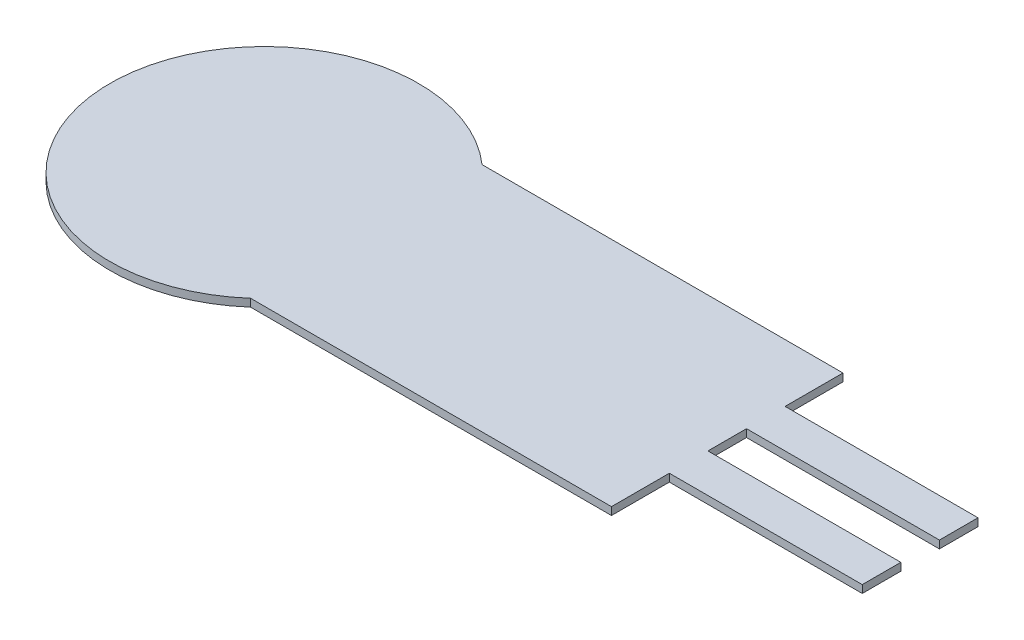
from build123d import *

# Parameters (mm, degrees)
SKETCH1_R           = 4
BOSS_EXTRUDE1_DEPTH = 0.1
SKETCH2_W           = 12
SKETCH2_H           = 6
BOSS_EXTRUDE2_DEPTH = 0.1
SKETCH3_W           = 5
SKETCH3_H           = 1
BOSS_EXTRUDE3_DEPTH = 0.1


with BuildPart() as part:
    # Sketch1 → Boss-Extrude1 (new body, symmetric)
    with BuildSketch(Plane(origin=(0, 0, 0), x_dir=(1, 0, 0), z_dir=(0, 1, 0))):
        Circle(SKETCH1_R)
    extrude(amount=BOSS_EXTRUDE1_DEPTH, both=True)

    # Sketch2 → Boss-Extrude2 (add, symmetric)
    with BuildSketch(Plane(origin=(0, 0, 0), x_dir=(1, 0, 0), z_dir=(0, 1, 0))):
        with Locations((6, 0)):
            Rectangle(SKETCH2_W, SKETCH2_H)
    extrude(amount=BOSS_EXTRUDE2_DEPTH, both=True)

    # Sketch3 → Boss-Extrude3 (add, symmetric)
    with BuildSketch(Plane(origin=(0, 0, 0), x_dir=(1, 0, 0), z_dir=(0, 1, 0))):
        with Locations((14.5, 1)):
            Rectangle(SKETCH3_W, SKETCH3_H)
    boss_extrude3 = extrude(amount=BOSS_EXTRUDE3_DEPTH, both=True)

    # Mirror1: Boss-Extrude3 across plane
    add(boss_extrude3.mirror(Plane.XY))


solid = part.part
